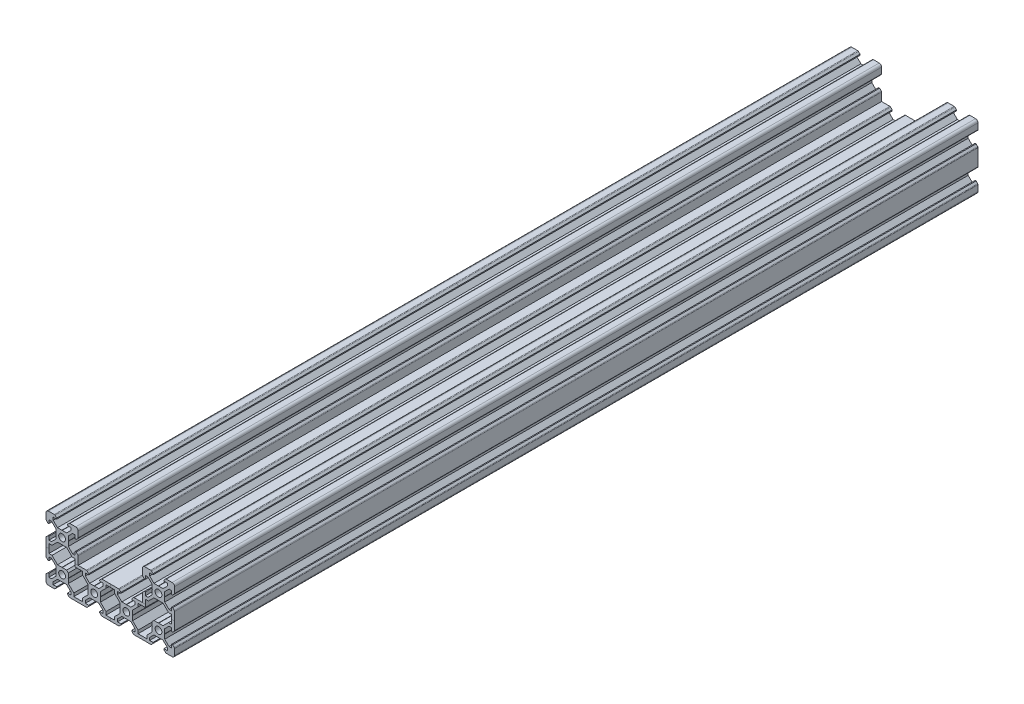
from build123d import *

# Parameters (mm, degrees)
SKETCH1_R           = 2.1
BOSS_EXTRUDE1_DEPTH = 500


with BuildPart() as part:
    # Sketch1 → Boss-Extrude1 (new body)
    with BuildSketch(Plane.XY):
        with BuildLine():
            Line((-2.8395, 3.9), (-0.1, 3.9))
            Line((-0.1, 3.9), (0, 3.8))
            Line((0, 3.8), (0.1, 3.9))
            Line((0.1, 3.9), (2.8395, 3.9))
            Line((2.8395, 3.9), (5.5005, 6.561))
            Line((5.5005, 6.561), (5.5005, 8.2))
            Line((5.5005, 8.2), (3.3865, 8.2))
            Line((3.3865, 8.2), (3.3865, 8.807))
            Line((3.3865, 8.807), (4.377060464, 9.797560464))
            ThreePointArc((4.377060464, 9.797560464), (4.601292737, 9.947387679), (4.865792737, 10))
            Line((4.865792737, 10), (8.5, 10))
            ThreePointArc((8.5, 10), (9.560660172, 9.560660172), (10, 8.5))
            Line((10, 8.5), (10, 4.862695796))
            ThreePointArc((10, 4.862695796), (9.947180343, 4.597695796), (9.796794374, 4.373198632))
            Line((9.796794374, 4.373198632), (8.807, 3.3865))
            Line((8.807, 3.3865), (8.2, 3.3865))
            Line((8.2, 3.3865), (8.2, 5.5005))
            Line((8.2, 5.5005), (6.561, 5.5005))
            Line((6.561, 5.5005), (3.9, 2.8395))
            Line((3.9, 2.8395), (3.9, 0.1))
            Line((3.9, 0.1), (3.8, 0))
            Line((3.8, 0), (3.9, -0.1))
            Line((3.9, -0.1), (3.9, -2.8395))
            Line((3.9, -2.8395), (6.561, -5.5005))
            Line((6.561, -5.5005), (8.2, -5.5005))
            Line((8.2, -5.5005), (8.2, -3.3865))
            Line((8.2, -3.3865), (8.807, -3.3865))
            Line((8.807, -3.3865), (9.797561312, -4.380169173))
            ThreePointArc((9.797561312, -4.380169173), (9.947396086, -4.604984013), (10, -4.869984013))
            Line((10, -4.869984013), (10, -10))
            Line((10, -10), (15.134207263, -10))
            ThreePointArc((15.134207263, -10), (15.398707263, -10.052612321), (15.622939536, -10.202439536))
            Line((15.622939536, -10.202439536), (16.6135, -11.193))
            Line((16.6135, -11.193), (16.6135, -11.8))
            Line((16.6135, -11.8), (14.4995, -11.8))
            Line((14.4995, -11.8), (14.4995, -13.439))
            Line((14.4995, -13.439), (17.1605, -16.1))
            Line((17.1605, -16.1), (19.9, -16.1))
            Line((19.9, -16.1), (20, -16.2))
            Line((20, -16.2), (20.1, -16.1))
            Line((20.1, -16.1), (22.8395, -16.1))
            Line((22.8395, -16.1), (25.5005, -13.439))
            Line((25.5005, -13.439), (25.5005, -11.8))
            Line((25.5005, -11.8), (23.3865, -11.8))
            Line((23.3865, -11.8), (23.3865, -11.193))
            Line((23.3865, -11.193), (24.377060464, -10.202439536))
            ThreePointArc((24.377060464, -10.202439536), (24.601292737, -10.052612321), (24.865792737, -10))
            Line((24.865792737, -10), (30, -10))
            Line((30, -10), (35.134207263, -10))
            ThreePointArc((35.134207263, -10), (35.398707263, -10.052612321), (35.622939536, -10.202439536))
            Line((35.622939536, -10.202439536), (36.6135, -11.193))
            Line((36.6135, -11.193), (36.6135, -11.8))
            Line((36.6135, -11.8), (34.4995, -11.8))
            Line((34.4995, -11.8), (34.4995, -13.439))
            Line((34.4995, -13.439), (37.1605, -16.1))
            Line((37.1605, -16.1), (39.9, -16.1))
            Line((39.9, -16.1), (40, -16.2))
            Line((40, -16.2), (40.1, -16.1))
            Line((40.1, -16.1), (42.8395, -16.1))
            Line((42.8395, -16.1), (45.5005, -13.439))
            Line((45.5005, -13.439), (45.5005, -11.8))
            Line((45.5005, -11.8), (43.3865, -11.8))
            Line((43.3865, -11.8), (43.3865, -11.193))
            Line((43.3865, -11.193), (44.377060464, -10.202439536))
            ThreePointArc((44.377060464, -10.202439536), (44.601292737, -10.052612321), (44.865792737, -10))
            Line((44.865792737, -10), (50, -10))
            Line((50, -10), (50, -4.869984013))
            ThreePointArc((50, -4.869984013), (50.052603914, -4.604984013), (50.202438688, -4.380169173))
            Line((50.202438688, -4.380169173), (51.193, -3.3865))
            Line((51.193, -3.3865), (51.8, -3.3865))
            Line((51.8, -3.3865), (51.8, -5.5005))
            Line((51.8, -5.5005), (53.439, -5.5005))
            Line((53.439, -5.5005), (56.1, -2.8395))
            Line((56.1, -2.8395), (56.1, -0.1))
            Line((56.1, -0.1), (56.2, 0))
            Line((56.2, 0), (56.1, 0.1))
            Line((56.1, 0.1), (56.1, 2.8395))
            Line((56.1, 2.8395), (53.439, 5.5005))
            Line((53.439, 5.5005), (51.8, 5.5005))
            Line((51.8, 5.5005), (51.8, 3.3865))
            Line((51.8, 3.3865), (51.193, 3.3865))
            Line((51.193, 3.3865), (50.203205626, 4.373198632))
            ThreePointArc((50.203205626, 4.373198632), (50.052819657, 4.597695796), (50, 4.862695796))
            Line((50, 4.862695796), (50, 8.5))
            ThreePointArc((50, 8.5), (50.439339828, 9.560660172), (51.5, 10))
            Line((51.5, 10), (55.134207263, 10))
            ThreePointArc((55.134207263, 10), (55.398707263, 9.947387679), (55.622939536, 9.797560464))
            Line((55.622939536, 9.797560464), (56.6135, 8.807))
            Line((56.6135, 8.807), (56.6135, 8.2))
            Line((56.6135, 8.2), (54.4995, 8.2))
            Line((54.4995, 8.2), (54.4995, 6.561))
            Line((54.4995, 6.561), (57.1605, 3.9))
            Line((57.1605, 3.9), (59.9, 3.9))
            Line((59.9, 3.9), (60, 3.8))
            Line((60, 3.8), (60.1, 3.9))
            Line((60.1, 3.9), (62.8395, 3.9))
            Line((62.8395, 3.9), (65.5005, 6.561))
            Line((65.5005, 6.561), (65.5005, 8.2))
            Line((65.5005, 8.2), (63.3865, 8.2))
            Line((63.3865, 8.2), (63.3865, 8.807))
            Line((63.3865, 8.807), (64.377060464, 9.797560464))
            ThreePointArc((64.377060464, 9.797560464), (64.601292737, 9.947387679), (64.865792737, 10))
            Line((64.865792737, 10), (68.5, 10))
            ThreePointArc((68.5, 10), (69.560660172, 9.560660172), (70, 8.5))
            Line((70, 8.5), (70, 4.862695796))
            ThreePointArc((70, 4.862695796), (69.947180343, 4.597695796), (69.796794374, 4.373198632))
            Line((69.796794374, 4.373198632), (68.807, 3.3865))
            Line((68.807, 3.3865), (68.2, 3.3865))
            Line((68.2, 3.3865), (68.2, 5.5005))
            Line((68.2, 5.5005), (66.561, 5.5005))
            Line((66.561, 5.5005), (63.9, 2.8395))
            Line((63.9, 2.8395), (63.9, 0.1))
            Line((63.9, 0.1), (63.8, 0))
            Line((63.8, 0), (63.9, -0.1))
            Line((63.9, -0.1), (63.9, -2.8395))
            Line((63.9, -2.8395), (66.561, -5.5005))
            Line((66.561, -5.5005), (68.2, -5.5005))
            Line((68.2, -5.5005), (68.2, -3.3865))
            Line((68.2, -3.3865), (68.807, -3.3865))
            Line((68.807, -3.3865), (69.797561312, -4.380169173))
            ThreePointArc((69.797561312, -4.380169173), (69.947396086, -4.604984013), (70, -4.869984013))
            Line((70, -4.869984013), (70, -15.130015987))
            ThreePointArc((70, -15.130015987), (69.947396086, -15.395015987), (69.797561312, -15.619830827))
            Line((69.797561312, -15.619830827), (68.807, -16.6135))
            Line((68.807, -16.6135), (68.2, -16.6135))
            Line((68.2, -16.6135), (68.2, -14.4995))
            Line((68.2, -14.4995), (66.561, -14.4995))
            Line((66.561, -14.4995), (63.9, -17.1605))
            Line((63.9, -17.1605), (63.9, -19.9))
            Line((63.9, -19.9), (63.8, -20))
            Line((63.8, -20), (63.9, -20.1))
            Line((63.9, -20.1), (63.9, -22.8395))
            Line((63.9, -22.8395), (66.561, -25.5005))
            Line((66.561, -25.5005), (68.2, -25.5005))
            Line((68.2, -25.5005), (68.2, -23.3865))
            Line((68.2, -23.3865), (68.807, -23.3865))
            Line((68.807, -23.3865), (69.796794374, -24.373198632))
            ThreePointArc((69.796794374, -24.373198632), (69.947180343, -24.597695796), (70, -24.862695796))
            Line((70, -24.862695796), (70, -28.5))
            ThreePointArc((70, -28.5), (69.560660172, -29.560660172), (68.5, -30))
            Line((68.5, -30), (64.865792737, -30))
            ThreePointArc((64.865792737, -30), (64.601292737, -29.947387679), (64.377060464, -29.797560464))
            Line((64.377060464, -29.797560464), (63.3865, -28.807))
            Line((63.3865, -28.807), (63.3865, -28.2))
            Line((63.3865, -28.2), (65.5005, -28.2))
            Line((65.5005, -28.2), (65.5005, -26.561))
            Line((65.5005, -26.561), (62.8395, -23.9))
            Line((62.8395, -23.9), (60.1, -23.9))
            Line((60.1, -23.9), (60, -23.8))
            Line((60, -23.8), (59.9, -23.9))
            Line((59.9, -23.9), (57.1605, -23.9))
            Line((57.1605, -23.9), (54.4995, -26.561))
            Line((54.4995, -26.561), (54.4995, -28.2))
            Line((54.4995, -28.2), (56.6135, -28.2))
            Line((56.6135, -28.2), (56.6135, -28.807))
            Line((56.6135, -28.807), (55.622939536, -29.797560464))
            ThreePointArc((55.622939536, -29.797560464), (55.398707263, -29.947387679), (55.134207263, -30))
            Line((55.134207263, -30), (50, -30))
            Line((50, -30), (44.865792737, -30))
            ThreePointArc((44.865792737, -30), (44.601292737, -29.947387679), (44.377060464, -29.797560464))
            Line((44.377060464, -29.797560464), (43.3865, -28.807))
            Line((43.3865, -28.807), (43.3865, -28.2))
            Line((43.3865, -28.2), (45.5005, -28.2))
            Line((45.5005, -28.2), (45.5005, -26.561))
            Line((45.5005, -26.561), (42.8395, -23.9))
            Line((42.8395, -23.9), (40.1, -23.9))
            Line((40.1, -23.9), (40, -23.8))
            Line((40, -23.8), (39.9, -23.9))
            Line((39.9, -23.9), (37.1605, -23.9))
            Line((37.1605, -23.9), (34.4995, -26.561))
            Line((34.4995, -26.561), (34.4995, -28.2))
            Line((34.4995, -28.2), (36.6135, -28.2))
            Line((36.6135, -28.2), (36.6135, -28.807))
            Line((36.6135, -28.807), (35.622939536, -29.797560464))
            ThreePointArc((35.622939536, -29.797560464), (35.398707263, -29.947387679), (35.134207263, -30))
            Line((35.134207263, -30), (30, -30))
            Line((30, -30), (24.865792737, -30))
            ThreePointArc((24.865792737, -30), (24.601292737, -29.947387679), (24.377060464, -29.797560464))
            Line((24.377060464, -29.797560464), (23.3865, -28.807))
            Line((23.3865, -28.807), (23.3865, -28.2))
            Line((23.3865, -28.2), (25.5005, -28.2))
            Line((25.5005, -28.2), (25.5005, -26.561))
            Line((25.5005, -26.561), (22.8395, -23.9))
            Line((22.8395, -23.9), (20.1, -23.9))
            Line((20.1, -23.9), (20, -23.8))
            Line((20, -23.8), (19.9, -23.9))
            Line((19.9, -23.9), (17.1605, -23.9))
            Line((17.1605, -23.9), (14.4995, -26.561))
            Line((14.4995, -26.561), (14.4995, -28.2))
            Line((14.4995, -28.2), (16.6135, -28.2))
            Line((16.6135, -28.2), (16.6135, -28.807))
            Line((16.6135, -28.807), (15.622939536, -29.797560464))
            ThreePointArc((15.622939536, -29.797560464), (15.398707263, -29.947387679), (15.134207263, -30))
            Line((15.134207263, -30), (10, -30))
            Line((10, -30), (4.865792737, -30))
            ThreePointArc((4.865792737, -30), (4.601292737, -29.947387679), (4.377060464, -29.797560464))
            Line((4.377060464, -29.797560464), (3.3865, -28.807))
            Line((3.3865, -28.807), (3.3865, -28.2))
            Line((3.3865, -28.2), (5.5005, -28.2))
            Line((5.5005, -28.2), (5.5005, -26.561))
            Line((5.5005, -26.561), (2.8395, -23.9))
            Line((2.8395, -23.9), (0.1, -23.9))
            Line((0.1, -23.9), (0, -23.8))
            Line((0, -23.8), (-0.1, -23.9))
            Line((-0.1, -23.9), (-2.8395, -23.9))
            Line((-2.8395, -23.9), (-5.5005, -26.561))
            Line((-5.5005, -26.561), (-5.5005, -28.2))
            Line((-5.5005, -28.2), (-3.3865, -28.2))
            Line((-3.3865, -28.2), (-3.3865, -28.807))
            Line((-3.3865, -28.807), (-4.377060464, -29.797560464))
            ThreePointArc((-4.377060464, -29.797560464), (-4.601292737, -29.947387679), (-4.865792737, -30))
            Line((-4.865792737, -30), (-8.5, -30))
            ThreePointArc((-8.5, -30), (-9.560660172, -29.560660172), (-10, -28.5))
            Line((-10, -28.5), (-10, -24.862695796))
            ThreePointArc((-10, -24.862695796), (-9.947180343, -24.597695796), (-9.796794374, -24.373198632))
            Line((-9.796794374, -24.373198632), (-8.807, -23.3865))
            Line((-8.807, -23.3865), (-8.2, -23.3865))
            Line((-8.2, -23.3865), (-8.2, -25.5005))
            Line((-8.2, -25.5005), (-6.561, -25.5005))
            Line((-6.561, -25.5005), (-3.9, -22.8395))
            Line((-3.9, -22.8395), (-3.9, -20.1))
            Line((-3.9, -20.1), (-3.8, -20))
            Line((-3.8, -20), (-3.9, -19.9))
            Line((-3.9, -19.9), (-3.9, -17.1605))
            Line((-3.9, -17.1605), (-6.561, -14.4995))
            Line((-6.561, -14.4995), (-8.2, -14.4995))
            Line((-8.2, -14.4995), (-8.2, -16.6135))
            Line((-8.2, -16.6135), (-8.807, -16.6135))
            Line((-8.807, -16.6135), (-9.797561312, -15.619830827))
            ThreePointArc((-9.797561312, -15.619830827), (-9.947396086, -15.395015987), (-10, -15.130015987))
            Line((-10, -15.130015987), (-10, -4.869984013))
            ThreePointArc((-10, -4.869984013), (-9.947396086, -4.604984013), (-9.797561312, -4.380169173))
            Line((-9.797561312, -4.380169173), (-8.807, -3.3865))
            Line((-8.807, -3.3865), (-8.2, -3.3865))
            Line((-8.2, -3.3865), (-8.2, -5.5005))
            Line((-8.2, -5.5005), (-6.561, -5.5005))
            Line((-6.561, -5.5005), (-3.9, -2.8395))
            Line((-3.9, -2.8395), (-3.9, -0.1))
            Line((-3.9, -0.1), (-3.8, 0))
            Line((-3.8, 0), (-3.9, 0.1))
            Line((-3.9, 0.1), (-3.9, 2.8395))
            Line((-3.9, 2.8395), (-6.561, 5.5005))
            Line((-6.561, 5.5005), (-8.2, 5.5005))
            Line((-8.2, 5.5005), (-8.2, 3.3865))
            Line((-8.2, 3.3865), (-8.807, 3.3865))
            Line((-8.807, 3.3865), (-9.796794374, 4.373198632))
            ThreePointArc((-9.796794374, 4.373198632), (-9.947180343, 4.597695796), (-10, 4.862695796))
            Line((-10, 4.862695796), (-10, 8.5))
            ThreePointArc((-10, 8.5), (-9.560660172, 9.560660172), (-8.5, 10))
            Line((-8.5, 10), (-4.865792737, 10))
            ThreePointArc((-4.865792737, 10), (-4.601292737, 9.947387679), (-4.377060464, 9.797560464))
            Line((-4.377060464, 9.797560464), (-3.3865, 8.807))
            Line((-3.3865, 8.807), (-3.3865, 8.2))
            Line((-3.3865, 8.2), (-5.5005, 8.2))
            Line((-5.5005, 8.2), (-5.5005, 6.561))
            Line((-5.5005, 6.561), (-2.8395, 3.9))
        make_face()
        Circle(SKETCH1_R, mode=Mode.SUBTRACT)
        with Locations((0, -20)):
            Circle(SKETCH1_R, mode=Mode.SUBTRACT)
        with Locations((20, -20)):
            Circle(SKETCH1_R, mode=Mode.SUBTRACT)
        with Locations((60, 0)):
            Circle(SKETCH1_R, mode=Mode.SUBTRACT)
        with Locations((60, -20)):
            Circle(SKETCH1_R, mode=Mode.SUBTRACT)
        with Locations((40, -20)):
            Circle(SKETCH1_R, mode=Mode.SUBTRACT)
        Polygon((-2.8395, -3.9), (-0.1, -3.9), (0, -3.8), (0.1, -3.9), (2.8395, -3.9), (5.5005, -6.561), (6.24, -7.3005), (8.2, -7.3005), (8.2, -11.8), (12.6995, -11.8), (12.6995, -13.76), (16.1, -17.1605), (16.1, -19.9), (16.2, -20), (16.1, -20.1), (16.1, -22.8395), (12.6995, -26.24), (12.6995, -28.2), (7.3005, -28.2), (7.3005, -26.24), (3.9, -22.8395), (3.9, -20.1), (3.8, -20), (3.9, -19.9), (3.9, -17.1605), (2.8395, -16.1), (0.1, -16.1), (0, -16.2), (-0.1, -16.1), (-2.8395, -16.1), (-6.24, -12.6995), (-8.2, -12.6995), (-8.2, -7.3005), (-6.24, -7.3005), (-5.5005, -6.561), align=None, mode=Mode.SUBTRACT)
        Polygon((23.9, -19.9), (23.9, -17.1605), (27.3005, -13.76), (27.3005, -11.8), (32.6995, -11.8), (32.6995, -13.76), (36.1, -17.1605), (36.1, -19.9), (36.2, -20), (36.1, -20.1), (36.1, -22.8395), (32.6995, -26.24), (32.6995, -28.2), (27.3005, -28.2), (27.3005, -26.24), (23.9, -22.8395), (23.9, -20.1), (23.8, -20), align=None, mode=Mode.SUBTRACT)
        Polygon((60, -3.8), (59.9, -3.9), (57.1605, -3.9), (54.4995, -6.561), (53.76, -7.3005), (51.8, -7.3005), (51.8, -11.8), (47.3005, -11.8), (47.3005, -13.76), (43.9, -17.1605), (43.9, -19.9), (43.8, -20), (43.9, -20.1), (43.9, -22.8395), (47.3005, -26.24), (47.3005, -28.2), (52.6995, -28.2), (52.6995, -26.24), (56.1, -22.8395), (56.1, -20.1), (56.2, -20), (56.1, -19.9), (56.1, -17.1605), (57.1605, -16.1), (59.9, -16.1), (60, -16.2), (60.1, -16.1), (62.8395, -16.1), (66.24, -12.6995), (68.2, -12.6995), (68.2, -7.3005), (66.24, -7.3005), (65.5005, -6.561), (62.8395, -3.9), (60.1, -3.9), align=None, mode=Mode.SUBTRACT)
    extrude(amount=BOSS_EXTRUDE1_DEPTH)


solid = part.part
